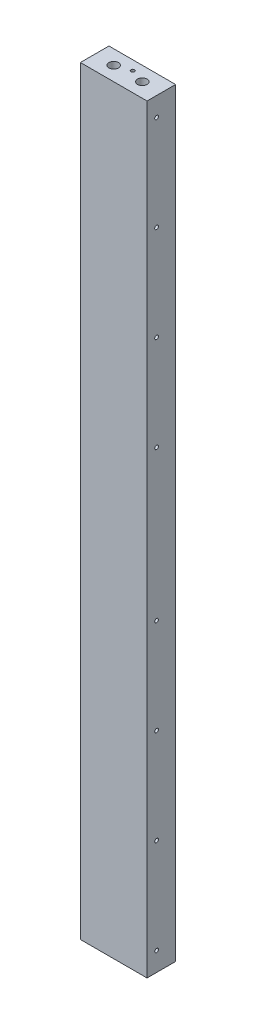
from build123d import *

# Parameters (mm, degrees)
SKETCH1_W                                  = 88.9
SKETCH1_H                                  = 38.1
BOSS_EXTRUDE1_DEPTH                        = 1012.825
SKETCH2_R                                  = 6.35
CUT_EXTRUDE1_DEPTH                         = 19.05
SKETCH3_R                                  = 6.35
CUT_EXTRUDE2_DEPTH                         = 19.05
F_10_0_1935_DIAMETER_HOLE1_D               = 4.9149
F_10_0_1935_DIAMETER_HOLE1_DEPTH           = 76.2
F_10_0_1935_DIAMETER_HOLE1_TIP             = 1.476584928
F_10_0_1935_DIAMETER_HOLE1_ON_FACE_2_D     = 4.9149
F_10_0_1935_DIAMETER_HOLE1_ON_FACE_2_DEPTH = 76.2
F_10_0_1935_DIAMETER_HOLE1_ON_FACE_2_TIP   = 1.476584928
F_10_0_1935_DIAMETER_HOLE2_D               = 4.9149
F_10_0_1935_DIAMETER_HOLE2_DEPTH           = 50.8
F_10_0_1935_DIAMETER_HOLE2_TIP             = 1.476584928


with BuildPart() as part:
    # Sketch1 → Boss-Extrude1 (new body)
    with BuildSketch(Plane(origin=(0, 0, 0), x_dir=(1, 0, 0), z_dir=(0, 1, 0))):
        with Locations((44.45, -19.05)):
            Rectangle(SKETCH1_W, SKETCH1_H)
    extrude(amount=BOSS_EXTRUDE1_DEPTH)

    # Sketch2 → Cut-Extrude1 (cut)
    with BuildSketch(Plane(origin=(0, 1012.825, 0), x_dir=(1, 0, 0), z_dir=(0, 1, 0))):
        with Locations((25.4, -19.05)):
            Circle(SKETCH2_R)
        with Locations((63.5, -19.05)):
            Circle(SKETCH2_R)
    extrude(amount=-CUT_EXTRUDE1_DEPTH, mode=Mode.SUBTRACT)

    # Sketch3 → Cut-Extrude2 (cut)
    with BuildSketch(Plane.XZ):
        with Locations((25.4, 19.05)):
            Circle(SKETCH3_R)
        with Locations((63.5, 19.05)):
            Circle(SKETCH3_R)
    extrude(amount=-CUT_EXTRUDE2_DEPTH, mode=Mode.SUBTRACT)

    # #10 (0.1935) Diameter Hole1
    with Locations(Plane(origin=(44.45, 1012.825, 12.7), x_dir=(0, 0, 1), z_dir=(0, 1, 0))):
        with Locations((0, 0)):
            Hole(F_10_0_1935_DIAMETER_HOLE1_D / 2, depth=F_10_0_1935_DIAMETER_HOLE1_DEPTH)
            with Locations((0, 0, -(F_10_0_1935_DIAMETER_HOLE1_DEPTH + F_10_0_1935_DIAMETER_HOLE1_TIP / 2))):  # 118° drill point
                Cone(0, F_10_0_1935_DIAMETER_HOLE1_D / 2, F_10_0_1935_DIAMETER_HOLE1_TIP, mode=Mode.SUBTRACT)

    # #10 (0.1935) Diameter Hole1 on face 2
    with Locations(Plane(origin=(12.7, 0, 19.05), x_dir=(0, 0, -1), z_dir=(0, -1, 0))):
        with Locations((0, 0), (6.35, 63.5)):
            Hole(F_10_0_1935_DIAMETER_HOLE1_ON_FACE_2_D / 2, depth=F_10_0_1935_DIAMETER_HOLE1_ON_FACE_2_DEPTH)
            with Locations((0, 0, -(F_10_0_1935_DIAMETER_HOLE1_ON_FACE_2_DEPTH + F_10_0_1935_DIAMETER_HOLE1_ON_FACE_2_TIP / 2))):  # 118° drill point
                Cone(0, F_10_0_1935_DIAMETER_HOLE1_ON_FACE_2_D / 2, F_10_0_1935_DIAMETER_HOLE1_ON_FACE_2_TIP, mode=Mode.SUBTRACT)

    # #10 (0.1935) Diameter Hole2
    with Locations(Plane(origin=(88.9, 987.425, 25.4), x_dir=(0, 0, 1), z_dir=(1, 0, 0))):
        with Locations((0, 0), (0, 127), (0, 254), (0, 381), (0, 581.025), (0, 708.025), (0, 835.025), (0, 962.025)):
            Hole(F_10_0_1935_DIAMETER_HOLE2_D / 2, depth=F_10_0_1935_DIAMETER_HOLE2_DEPTH)
            with Locations((0, 0, -(F_10_0_1935_DIAMETER_HOLE2_DEPTH + F_10_0_1935_DIAMETER_HOLE2_TIP / 2))):  # 118° drill point
                Cone(0, F_10_0_1935_DIAMETER_HOLE2_D / 2, F_10_0_1935_DIAMETER_HOLE2_TIP, mode=Mode.SUBTRACT)


solid = part.part
